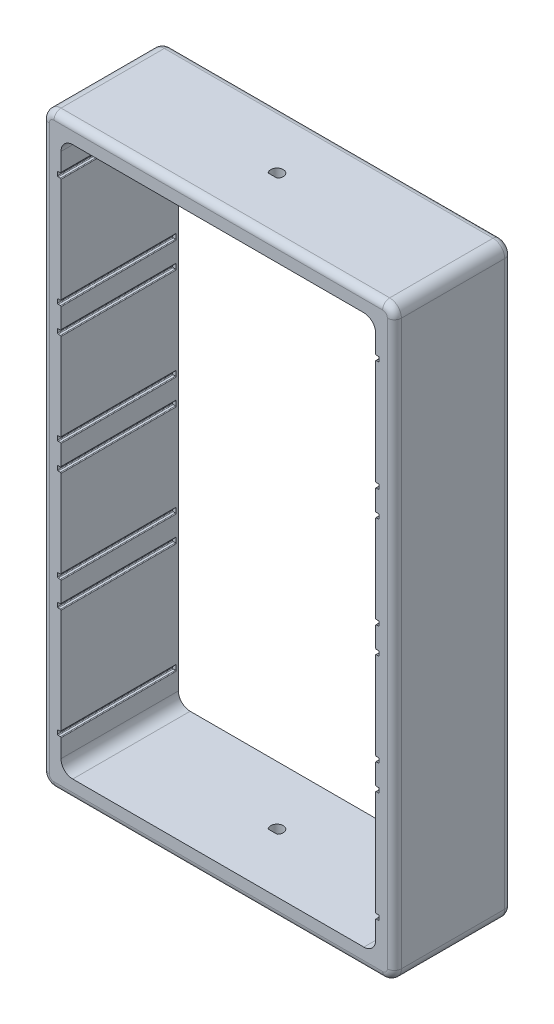
from build123d import *

# Parameters (mm, degrees)
SKETCH1_W           = 150
SKETCH1_H           = 250
BOSS_EXTRUDE1_DEPTH = 25
SKETCH2_W           = 134
SKETCH2_H           = 234
CUT_EXTRUDE1_DEPTH  = 51
CUT_EXTRUDE2_DEPTH  = 251
SKETCH7_W           = 1.5
SKETCH7_H           = 2
CUT_EXTRUDE5_DEPTH  = 49
FILLET1_R           = 5
FILLET2_R           = 3
FILLET3_R           = 0.3


with BuildPart() as part:
    # Sketch1 → Boss-Extrude1 (new body, symmetric)
    with BuildSketch(Plane.XY):
        with Locations((75, 125)):
            Rectangle(SKETCH1_W, SKETCH1_H)
    extrude(amount=BOSS_EXTRUDE1_DEPTH, both=True)

    # Sketch2 → Cut-Extrude1 (cut, through all)
    with BuildSketch(Plane.XY.offset(25)):
        with Locations((75, 125)):
            Rectangle(SKETCH2_W, SKETCH2_H)
    extrude(amount=-CUT_EXTRUDE1_DEPTH, mode=Mode.SUBTRACT)

    # Sketch3 → Cut-Extrude2 (cut, through all)
    with BuildSketch(Plane(origin=(0, 250, 0), x_dir=(1, 0, 0), z_dir=(0, 1, 0))):
        with BuildLine():
            Line((73.09, -1.836954001), (76.91, -1.836954001))
            ThreePointArc((76.91, -1.836954001), (75, 2.65), (73.09, -1.836954001))
        make_face()
    extrude(amount=-CUT_EXTRUDE2_DEPTH, mode=Mode.SUBTRACT)

    # Sketch7 → Cut-Extrude5 (cut)
    with BuildSketch(Plane.XY.offset(25)):
        with Locations((7.25, 181)):
            Rectangle(SKETCH7_W, SKETCH7_H)
        with Locations((7.25, 228)):
            Rectangle(SKETCH7_W, SKETCH7_H)
        with Locations((7.25, 170)):
            Rectangle(SKETCH7_W, SKETCH7_H)
        with Locations((7.25, 80)):
            Rectangle(SKETCH7_W, SKETCH7_H)
        with Locations((7.25, 22)):
            Rectangle(SKETCH7_W, SKETCH7_H)
        with Locations((7.25, 69)):
            Rectangle(SKETCH7_W, SKETCH7_H)
        with Locations((7.25, 130.5)):
            Rectangle(SKETCH7_W, SKETCH7_H)
        with Locations((7.25, 119.5)):
            Rectangle(SKETCH7_W, SKETCH7_H)
        with Locations((142.75, 119.5)):
            Rectangle(SKETCH7_W, SKETCH7_H)
        with Locations((142.75, 130.5)):
            Rectangle(SKETCH7_W, SKETCH7_H)
        with Locations((142.75, 69)):
            Rectangle(SKETCH7_W, SKETCH7_H)
        with Locations((142.75, 22)):
            Rectangle(SKETCH7_W, SKETCH7_H)
        with Locations((142.75, 80)):
            Rectangle(SKETCH7_W, SKETCH7_H)
        with Locations((142.75, 170)):
            Rectangle(SKETCH7_W, SKETCH7_H)
        with Locations((142.75, 181)):
            Rectangle(SKETCH7_W, SKETCH7_H)
        with Locations((142.75, 228)):
            Rectangle(SKETCH7_W, SKETCH7_H)
    extrude(amount=-CUT_EXTRUDE5_DEPTH, mode=Mode.SUBTRACT)

    # Fillet1
    fillet1_edges = [part.edges().sort_by_distance(p)[0] for p in [
        (142, 242, 0),
        (142, 8, 0),
        (8, 8, 0),
        (8, 242, 0),
        (0, 250, 0),
        (150, 250, 0),
        (150, 0, 0),
        (0, 0, 0),
    ]]
    fillet(fillet1_edges, radius=FILLET1_R)

    # Fillet2
    fillet2_edges = [part.edges().sort_by_distance(p)[0] for p in [
        (150, 125, -25),
        (150, 125, 25),
        (0, 125, -25),
        (75, 250, -25),
        (75, 0, -25),
        (1.464466094, 248.535533906, -25),
        (148.535533906, 248.535533906, -25),
        (1.464466094, 1.464466094, -25),
        (148.535533906, 1.464466094, -25),
        (75, 0, 25),
        (0, 125, 25),
        (75, 250, 25),
        (1.464466094, 248.535533906, 25),
        (148.535533906, 248.535533906, 25),
        (1.464466094, 1.464466094, 25),
        (148.535533906, 1.464466094, 25),
    ]]
    fillet(fillet2_edges, radius=FILLET2_R)

    # Fillet3
    fillet3_edges = [part.edges().sort_by_distance(p)[0] for p in [
        (6.5, 70, 0.5),
        (8, 70, 0.5),
        (6.5, 129.5, 0.5),
        (6.5, 131.5, 0.5),
        (8, 131.5, 0.5),
        (8, 129.5, 0.5),
        (6.5, 118.5, 0.5),
        (6.5, 120.5, 0.5),
        (8, 120.5, 0.5),
        (8, 118.5, 0.5),
        (143.5, 131.5, 0.5),
        (143.5, 129.5, 0.5),
        (142, 129.5, 0.5),
        (142, 131.5, 0.5),
        (8, 21, 0.5),
        (6.5, 21, 0.5),
        (6.5, 23, 0.5),
        (8, 23, 0.5),
        (6.5, 79, 0.5),
        (6.5, 81, 0.5),
        (8, 81, 0.5),
        (8, 79, 0.5),
        (6.5, 169, 0.5),
        (6.5, 171, 0.5),
        (8, 171, 0.5),
        (8, 169, 0.5),
        (6.5, 227, 0.5),
        (6.5, 229, 0.5),
        (8, 229, 0.5),
        (8, 227, 0.5),
        (143.5, 81, 0.5),
        (143.5, 79, 0.5),
        (142, 79, 0.5),
        (142, 81, 0.5),
        (143.5, 23, 0.5),
        (143.5, 21, 0.5),
        (142, 21, 0.5),
        (142, 23, 0.5),
        (143.5, 70, 0.5),
        (143.5, 68, 0.5),
        (142, 68, 0.5),
        (142, 70, 0.5),
        (142, 120.5, 0.5),
        (143.5, 120.5, 0.5),
        (143.5, 118.5, 0.5),
        (142, 118.5, 0.5),
        (142, 171, 0.5),
        (143.5, 171, 0.5),
        (143.5, 169, 0.5),
        (142, 169, 0.5),
        (142, 182, 0.5),
        (143.5, 182, 0.5),
        (143.5, 180, 0.5),
        (142, 180, 0.5),
        (142, 229, 0.5),
        (143.5, 229, 0.5),
        (143.5, 227, 0.5),
        (142, 227, 0.5),
        (6.5, 180, 0.5),
        (6.5, 182, 0.5),
        (8, 182, 0.5),
        (8, 180, 0.5),
        (8, 68, 0.5),
        (6.5, 68, 0.5),
    ]]
    fillet(fillet3_edges, radius=FILLET3_R)


solid = part.part
